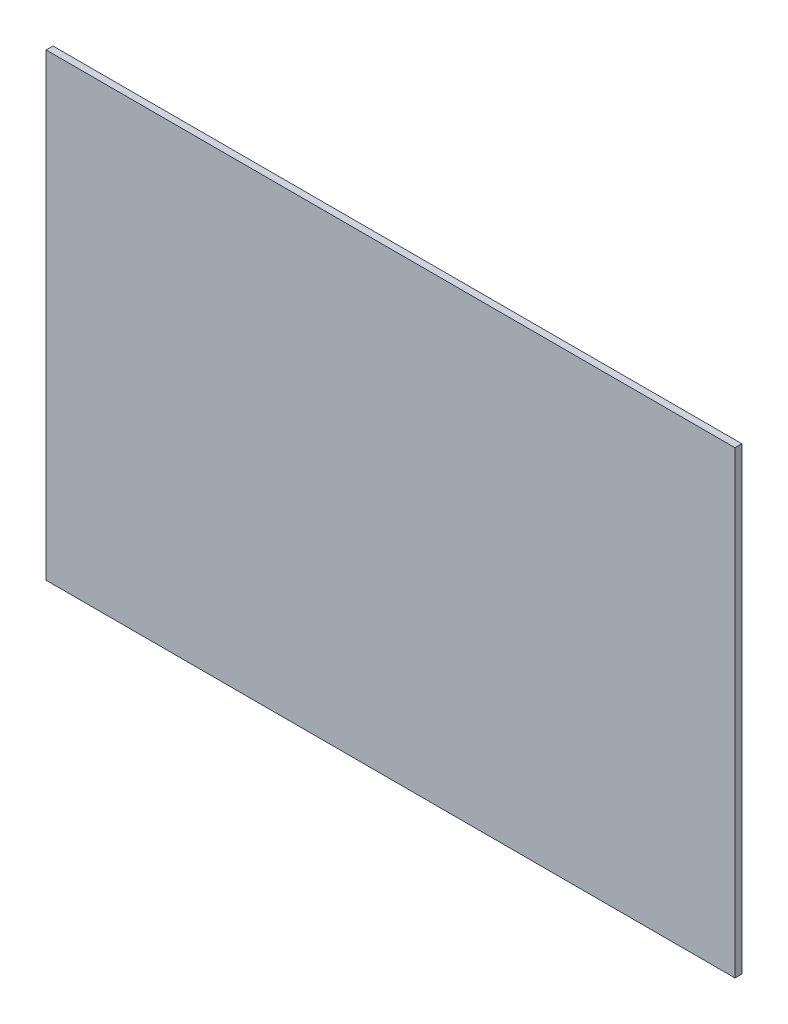
from build123d import *

# Parameters (mm, degrees)
ESQUISSE1_W        = 300
ESQUISSE1_H        = 200
BOSS_EXTRU_1_DEPTH = 3


with BuildPart() as part:
    # Esquisse1 → Boss.-Extru.1 (new body)
    with BuildSketch(Plane.XY):
        with Locations((90.451715498, 84.807037037)):
            Rectangle(ESQUISSE1_W, ESQUISSE1_H)
    extrude(amount=BOSS_EXTRU_1_DEPTH)


solid = part.part
